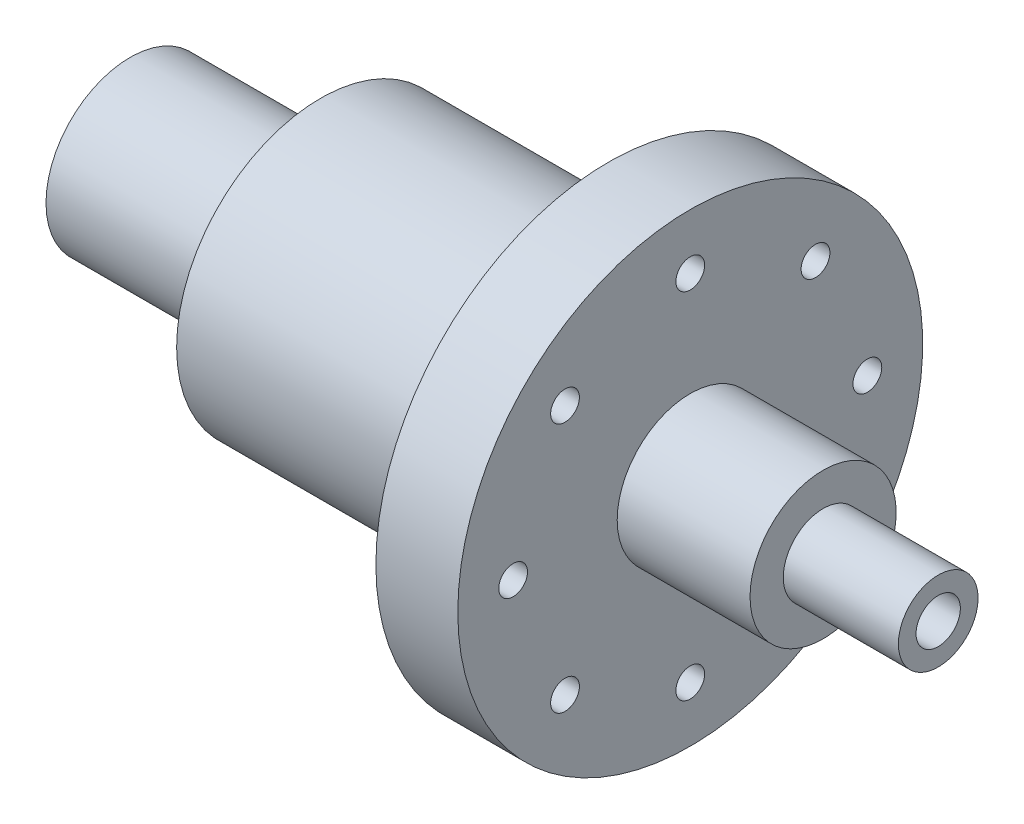
from build123d import *

# Parameters (mm, degrees)
SKETCH2_R          = 6.5
CUT_EXTRUDE1_DEPTH = 254


with BuildPart() as part:
    # Sketch1 → Revolve1 (revolve)
    with BuildSketch(Plane.XY):
        Polygon((-182.5, 10), (-182.5, 38), (-96.5, 38), (-96.5, 65), (33.5, 65), (33.5, 105), (70.5, 105), (70.5, 33), (130.5, 33), (130.5, 18), (182.5, 18), (182.5, 10), align=None)
    revolve(axis=Axis((-194.069566155, 0, 0), (1, 0, 0)))

    # Sketch2 → Cut-Extrude1 (cut, through all)
    with BuildSketch(Plane(origin=(70.5, 0, 0), x_dir=(0, 0, -1), z_dir=(1, 0, 0))):
        with Locations((0, 80)):
            Circle(SKETCH2_R)
        with Locations((56.568542495, 56.568542495)):
            Circle(SKETCH2_R)
        with Locations((80, 0)):
            Circle(SKETCH2_R)
        with Locations((56.568542495, -56.568542495)):
            Circle(SKETCH2_R)
        with Locations((0, -80)):
            Circle(SKETCH2_R)
        with Locations((-56.568542495, -56.568542495)):
            Circle(SKETCH2_R)
        with Locations((-80, 0)):
            Circle(SKETCH2_R)
        with Locations((-56.568542495, 56.568542495)):
            Circle(SKETCH2_R)
    extrude(amount=-CUT_EXTRUDE1_DEPTH, mode=Mode.SUBTRACT)


solid = part.part
